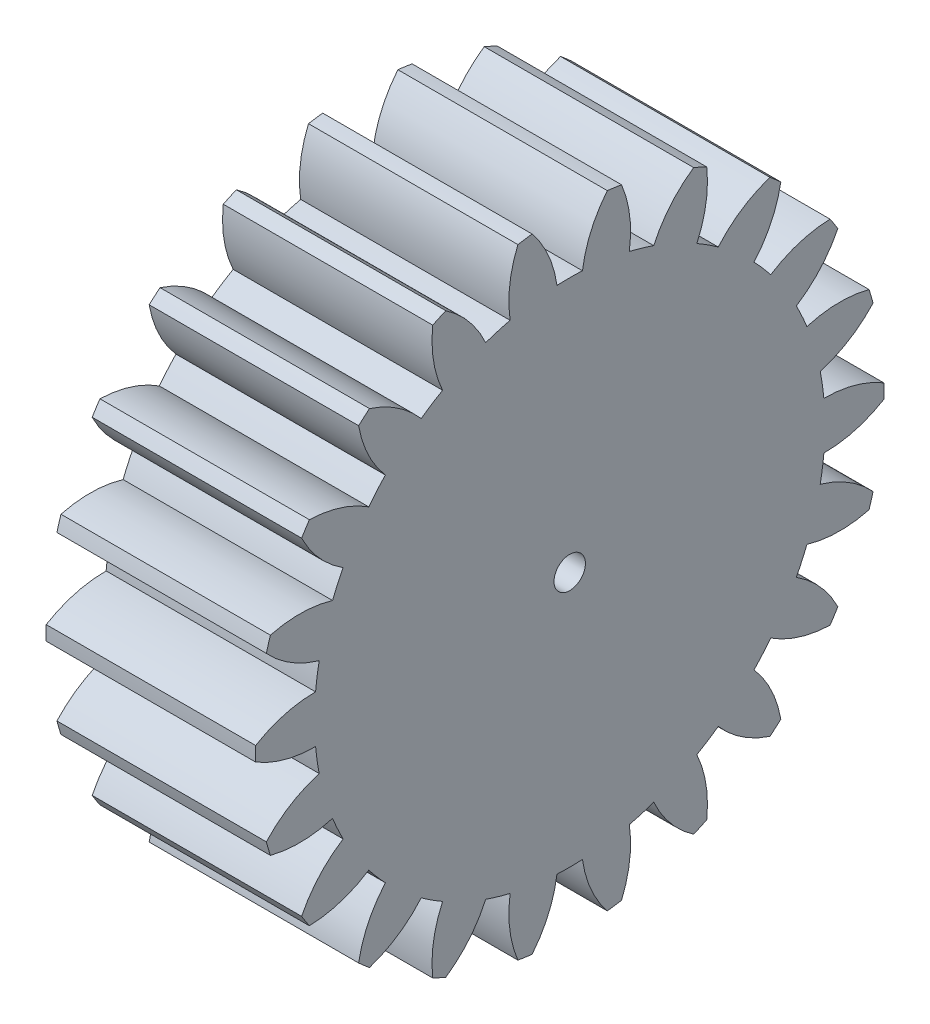
from build123d import *

# Parameters (mm, degrees)
BASPROSKE_W     = 20
BASPROSKE_H     = 30
TOOTHCUT_DEPTH  = 47.904157598
TEETHCUTS_COUNT = 22
TEETHCUTS_ANGLE = 343.636363636
BORSKE_R        = 1.5
BORE_DEPTH      = 50.0000508


with BuildPart() as part:
    # BasProSke → Base-Revolve (revolve)
    with BuildSketch(Plane(origin=(0, 0, 0), x_dir=(1, 0, 0), z_dir=(0, 1, 0)), mode=Mode.PRIVATE) as base_revolve_sk:
        with Locations((10, 15)):
            Rectangle(BASPROSKE_W, BASPROSKE_H)
    revolve(base_revolve_sk.sketch.rotate(Axis((-10, 0, 0), (1, 0, 0)), 180), axis=Axis((-10, 0, 0), (1, 0, 0)))

    # TooCutSke → ToothCut (cut, through all)
    with BuildSketch(Plane(origin=(0, 0, 0), x_dir=(0, 0, -1), z_dir=(1, 0, 0))):
        with BuildLine():
            ThreePointArc((1.215293185, 24.343683749), (0, 24.374), (-1.215293185, 24.343683749))
            ThreePointArc((-1.215293185, 24.343683749), (-2.034367134, 27.241050063), (-3.608361155, 29.807790507))
            ThreePointArc((-3.608361155, 29.807790507), (0, 30.0254), (3.608361155, 29.807790507))
            ThreePointArc((3.608361155, 29.807790507), (2.034367134, 27.241050063), (1.215293185, 24.343683749))
        make_face()
    toothcut = extrude(amount=TOOTHCUT_DEPTH, mode=Mode.SUBTRACT)

    # TeethCuts: ToothCut ×22 about axis
    teethcuts_axis = Axis((-10, 0, 0), (1, 0, 0))
    for i in range(1, TEETHCUTS_COUNT):
        add(toothcut.rotate(teethcuts_axis, i * TEETHCUTS_ANGLE / (TEETHCUTS_COUNT - 1)), mode=Mode.SUBTRACT)

    # BorSke → Bore (cut, symmetric)
    with BuildSketch(Plane(origin=(0, 0, 0), x_dir=(0, 0, -1), z_dir=(1, 0, 0))):
        with Locations(Location((0, 0, 0), (0, 0, 180))):
            Circle(BORSKE_R)
    extrude(amount=BORE_DEPTH, both=True, mode=Mode.SUBTRACT)


solid = part.part
